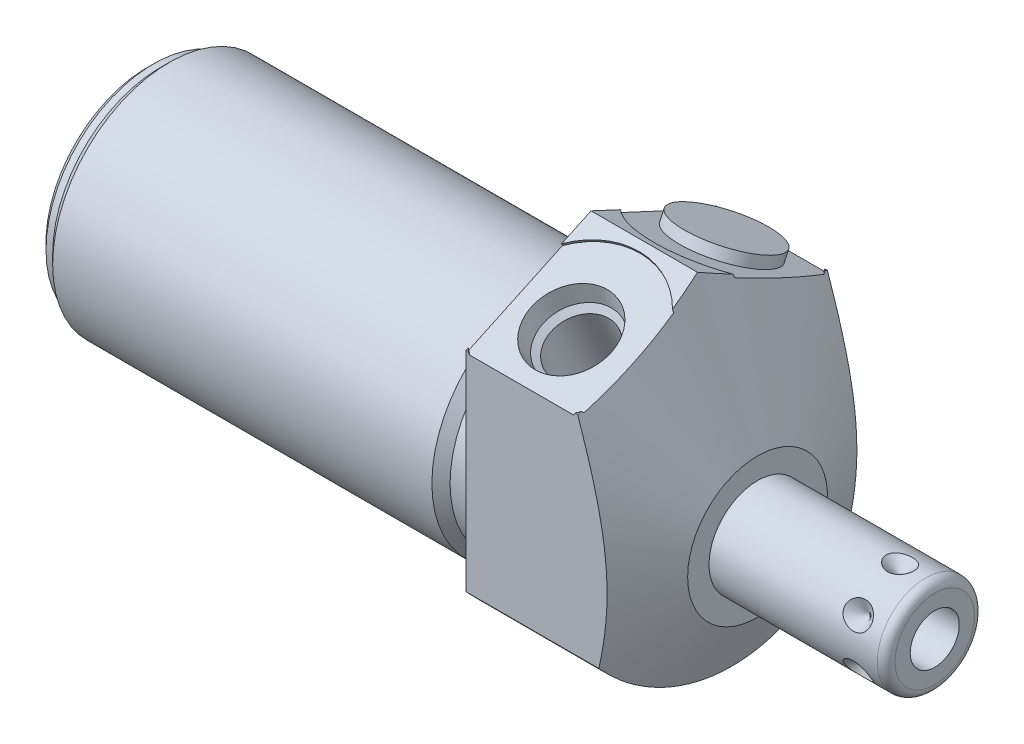
from build123d import *

# Parameters (mm, degrees)
SKETCH1_R           = 19.05
EXTRUDE1_DEPTH      = 19.05
EXTRUDE1_DEPTH_BACK = 50.8
CUT_EXTRUDE1_REACH  = 52.8
SKETCH2_R           = 19.05
SKETCH2_R_2         = 13.3604
CUT_EXTRUDE3_REACH  = 21.05
SKETCH19_R          = 8.6614
CUT_EXTRUDE4_DEPTH  = 0.254
SKETCH20_R          = 8.6614
CUT_EXTRUDE5_DEPTH  = 0.254
CHAMFER1_SIZE       = 0.762
SKETCH15_R          = 5.3086
EXTRUDE2_DEPTH      = 1.27
CIRPATTERN1_COUNT   = 6


with BuildPart() as part:
    # Sketch1 → Extrude1 (new body, two sides)
    with BuildSketch(Plane(origin=(0, 0, 0), x_dir=(0, 0, -1), z_dir=(1, 0, 0))) as extrude1_sk:
        Circle(SKETCH1_R)
    extrude(amount=EXTRUDE1_DEPTH)
    extrude(extrude1_sk.sketch, amount=-EXTRUDE1_DEPTH_BACK)

    # Sketch2 → Cut-Extrude1 (cut, up to next)
    with BuildSketch(Plane(origin=(0, 0, 0), x_dir=(0, 0, -1), z_dir=(1, 0, 0)), mode=Mode.PRIVATE) as cut_extrude1_sk1:
        Circle(SKETCH2_R)
        with Locations((0, -4.7498)):
            Circle(SKETCH2_R_2, mode=Mode.SUBTRACT)
    cut_extrude1_tool1 = extrude(cut_extrude1_sk1.sketch, amount=-CUT_EXTRUDE1_REACH, mode=Mode.PRIVATE) & part.part
    add(cut_extrude1_tool1.solids().sort_by_distance((0, 0, 18.511185))[0], mode=Mode.SUBTRACT)

    # Sketch4 → Cut-Extrude3 (cut, up to next)
    with BuildSketch(Plane.ZY, mode=Mode.PRIVATE) as cut_extrude3_sk1:
        with BuildLine():
            Line((14.2875, -12.600390619), (14.2875, 11.344778237))
            Line((14.2875, 11.344778237), (0, 18.007148903))
            Line((0, 18.007148903), (-14.2875, 11.344778237))
            Line((-14.2875, 11.344778237), (-14.2875, -12.600390619))
            ThreePointArc((-14.2875, -12.600390619), (0, 19.05), (14.2875, -12.600390619))
        make_face()
    cut_extrude3_tool1 = extrude(cut_extrude3_sk1.sketch, amount=-CUT_EXTRUDE3_REACH, mode=Mode.PRIVATE) & part.part
    add(cut_extrude3_tool1.solids().sort_by_distance((0, -0.627806, 14.782814))[0], mode=Mode.SUBTRACT)

    # Sketch6 → Cut-Revolve2 (revolve, cut)
    with BuildSketch(Plane.XY, mode=Mode.PRIVATE) as cut_revolve2_sk:
        Polygon((12.169188023, 18.007148903), (19.05, 3.2512), (19.05, 18.007148903), align=None)
    revolve(cut_revolve2_sk.sketch.rotate(Axis((1.987224567, -4.7498, 0), (1, 0, 0)), 270), axis=Axis((1.987224567, -4.7498, 0), (1, 0, 0)), mode=Mode.SUBTRACT)  # turned: the seam where the file's is

    # S2D0002 → Cut-Revolve3 (revolve, cut)
    with BuildSketch(Plane(origin=(6.35, 13.712414668, 8.609072086), x_dir=(0, 0.422618262, -0.906307787), z_dir=(1, 0, 0))):
        Polygon((0, 0), (4.5466, 0), (4.106586662, -2.0701), (3.4544, -2.722286662), (3.4544, -12.192), (0, -12.192), align=None)
    revolve(axis=Axis((6.35, 2.110224902, 3.198882147), (0, 0.906307787, 0.422618262)), mode=Mode.SUBTRACT)

    # Sketch19 → Cut-Extrude4 (cut)
    with BuildSketch(Plane(origin=(0, 14.790960552, 6.897138177), x_dir=(1, 0, 0), z_dir=(0, 0.906307787, 0.422618262))):
        with Locations((6.35, -2.00735222)):
            Circle(SKETCH19_R)
    extrude(amount=-CUT_EXTRUDE4_DEPTH, mode=Mode.SUBTRACT)

    # Sketch8 → Cut-Revolve4 (revolve, cut)
    with BuildSketch(Plane(origin=(6.35, 13.712414668, -8.609072086), x_dir=(0, -0.422618262, -0.906307787), z_dir=(1, 0, 0))):
        Polygon((0, 0), (4.5466, 0), (4.106586662, -2.0701), (3.4544, -2.722286662), (3.4544, -12.192), (0, -12.192), align=None)
    revolve(axis=Axis((6.35, 2.110224902, -3.198882147), (0, 0.906307787, -0.422618262)), mode=Mode.SUBTRACT)

    # Sketch20 → Cut-Extrude5 (cut)
    with BuildSketch(Plane(origin=(0, 14.790960552, -6.897138177), x_dir=(1, 0, 0), z_dir=(0, 0.906307787, -0.422618262))):
        with Locations((6.35, 2.00735222)):
            Circle(SKETCH20_R)
    extrude(amount=-CUT_EXTRUDE5_DEPTH, mode=Mode.SUBTRACT)

    # Sketch10 → Cut-Revolve6 (revolve, cut)
    with BuildSketch(Plane.XY, mode=Mode.PRIVATE) as cut_revolve6_sk:
        Polygon((0, 8.6106), (0, 7.5692), (-3.81, 7.5692), (-4.8514, 8.6106), align=None)
    revolve(cut_revolve6_sk.sketch.rotate(Axis((-5.09397, -4.7498, 0), (1, 0, 0)), 90), axis=Axis((-5.09397, -4.7498, 0), (1, 0, 0)), mode=Mode.SUBTRACT)  # turned: the seam where the file's is

    # Sketch12 → Cut-Revolve8 (revolve, cut)
    with BuildSketch(Plane.XY, mode=Mode.PRIVATE) as cut_revolve8_sk:
        Polygon((-50.8, 8.6106), (-50.8, 7.5692), (-49.276, 7.5692), (-48.2346, 8.6106), align=None)
    revolve(cut_revolve8_sk.sketch.rotate(Axis((-50.92827, -4.7498, 0), (1, 0, 0)), 90), axis=Axis((-50.92827, -4.7498, 0), (1, 0, 0)), mode=Mode.SUBTRACT)  # turned: the seam where the file's is

    # Chamfer1
    chamfer1_edges = [part.edges().sort_by_distance(p)[0] for p in [
        (-50.8, -4.7498, -12.319),
    ]]
    chamfer(chamfer1_edges, length=CHAMFER1_SIZE)

    # Sketch13 → Revolve1 (revolve)
    with BuildSketch(Plane(origin=(0, 0, 0), x_dir=(0, -1, 0), z_dir=(0, 0, 1)), mode=Mode.PRIVATE) as revolve1_sk:
        with BuildLine():
            Line((4.7498, 19.05), (4.7498, 39.3192))
            Line((4.7498, 39.3192), (9.29005, 39.3192))
            ThreePointArc((9.29005, 39.3192), (10.00847049, 39.02162049), (10.30605, 38.3032))
            Line((10.30605, 38.3032), (10.30605, 19.05))
            Line((10.30605, 19.05), (4.7498, 19.05))
        make_face()
    revolve(revolve1_sk.sketch.rotate(Axis((18.03654, -4.7498, 0), (1, 0, 0)), 270), axis=Axis((18.03654, -4.7498, 0), (1, 0, 0)))  # turned: the seam where the file's is

    # S2D0001 → Cut-Revolve9 (revolve, cut)
    with BuildSketch(Plane(origin=(39.3192, -7.5565, 0), x_dir=(0, -1, 0), z_dir=(0, 0, 1)), mode=Mode.PRIVATE) as cut_revolve9_sk:
        Polygon((0, 0), (0, -10.16), (-2.8067, -11.846435499), (-2.8067, 0), align=None)
    revolve(cut_revolve9_sk.sketch.rotate(Axis((26.880442726, -4.7498, 0), (1, 0, 0)), 270), axis=Axis((26.880442726, -4.7498, 0), (1, 0, 0)), mode=Mode.SUBTRACT)  # turned: the seam where the file's is

    # Sketch15 → Extrude2 (add)
    with BuildSketch(Plane(origin=(19.05, 14.560758374, -6.789793138), x_dir=(0, -0.422618262, -0.906307787), z_dir=(0, -0.906307787, 0.422618262))):
        with Locations((2.00735222, -12.7)):
            Circle(SKETCH15_R)
    extrude(amount=-EXTRUDE2_DEPTH)

    # Sketch16 → Cut-Revolve10 (revolve, cut)
    with BuildSketch(Plane(origin=(35.3568, 0.80645, 0), x_dir=(-1, 0, 0), z_dir=(0, 0, -1)), mode=Mode.PRIVATE) as cut_revolve10_sk:
        Polygon((0, 0), (1.5875, 0), (0, -1.5875), align=None)
    cut_revolve10 = revolve(cut_revolve10_sk.sketch.rotate(Axis((35.3568, -2.672346388, 0), (0, 1, 0)), 90), axis=Axis((35.3568, -2.672346388, 0), (0, 1, 0)), mode=Mode.SUBTRACT)  # turned: the seam where the file's is

    # CirPattern1: Cut-Revolve10 ×6 about axis
    cirpattern1_axis = Axis((18.03654, -4.7498, 0), (-1, 0, 0))
    for i in range(1, CIRPATTERN1_COUNT):
        add(cut_revolve10.rotate(cirpattern1_axis, i * 360 / CIRPATTERN1_COUNT), mode=Mode.SUBTRACT)


solid = part.part
